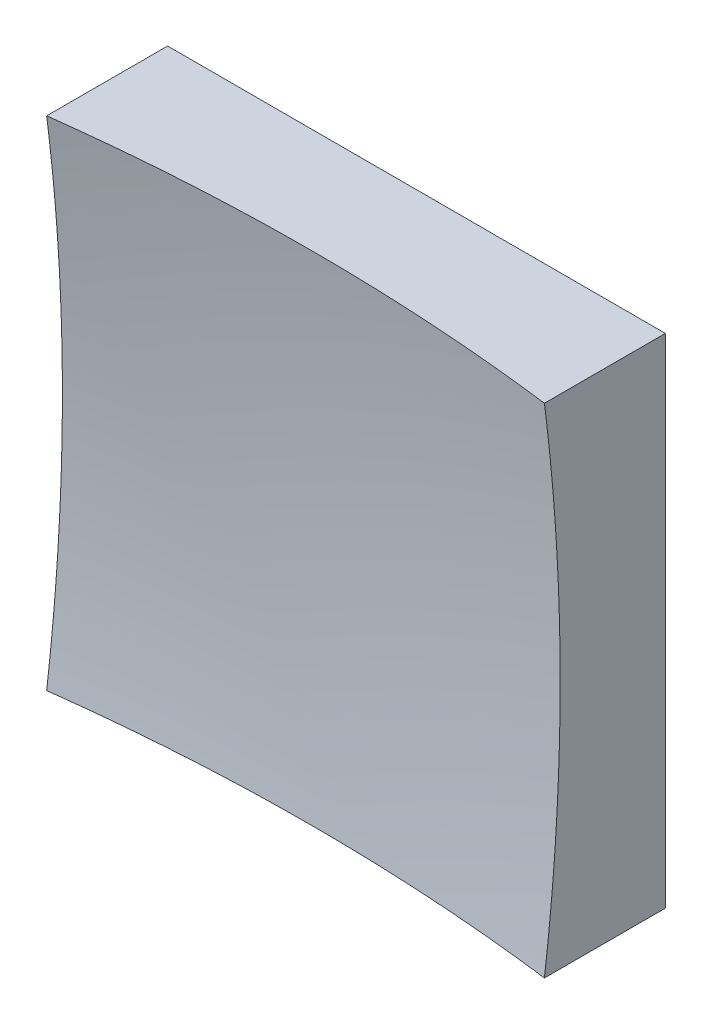
from build123d import *

# Parameters (mm, degrees)
SKETCH_1_W      = 50
SKETCH_1_H      = 50
EXTRUDE_1_DEPTH = 50


with BuildPart() as part:
    # 草图1 → 凸台-拉伸1 (new body)
    with BuildSketch(Plane.XY):
        Rectangle(SKETCH_1_W, SKETCH_1_H)
    extrude(amount=EXTRUDE_1_DEPTH)

    # 草图2 → 切除-旋转2 (revolve, cut)
    with BuildSketch(Plane(origin=(0, 0, 0), x_dir=(1, 0, 0), z_dir=(0, 1, 0))):
        with BuildLine():
            Line((194.969092363, -164.423627073), (0, -164.423627073))
            Line((0, -164.423627073), (0, -9))
            ThreePointArc((0, -9), (124.669012619, -52.610622827), (194.969092363, -164.423627073))
        make_face()
    revolve(axis=Axis((0, 0, 164.423627073), (0, 0, -1)), mode=Mode.SUBTRACT)


solid = part.part
